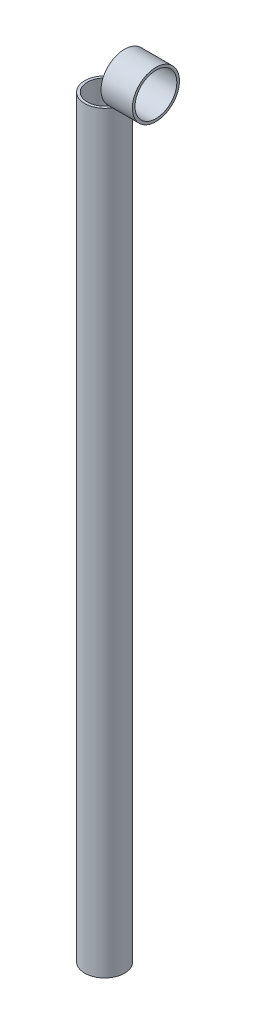
from build123d import *

# Parameters (mm, degrees)
SKETCH1_R           = 24.13
SKETCH1_R_2         = 20.955
BOSS_EXTRUDE1_DEPTH = 914.4
BOSS_EXTRUDE2_START = 24.13
SKETCH2_R           = 28.575
SKETCH2_R_2         = 25.4
BOSS_EXTRUDE2_DEPTH = 38.1


with BuildPart() as part:
    # Sketch1 → Boss-Extrude1 (new body)
    with BuildSketch(Plane(origin=(0, 0, 0), x_dir=(1, 0, 0), z_dir=(0, 1, 0))):
        Circle(SKETCH1_R)
        Circle(SKETCH1_R_2, mode=Mode.SUBTRACT)
    extrude(amount=BOSS_EXTRUDE1_DEPTH)


with BuildPart() as body_2:
    # Sketch2 → Boss-Extrude2 (new body)
    with BuildSketch(Plane(origin=(0, 0, 0), x_dir=(0, 0, -1), z_dir=(1, 0, 0)).offset(BOSS_EXTRUDE2_START)):
        with Locations((0, 942.975)):
            Circle(SKETCH2_R)
        with Locations((0, 942.975)):
            Circle(SKETCH2_R_2, mode=Mode.SUBTRACT)
    extrude(amount=BOSS_EXTRUDE2_DEPTH)


solid = Compound([part.part, body_2.part])
